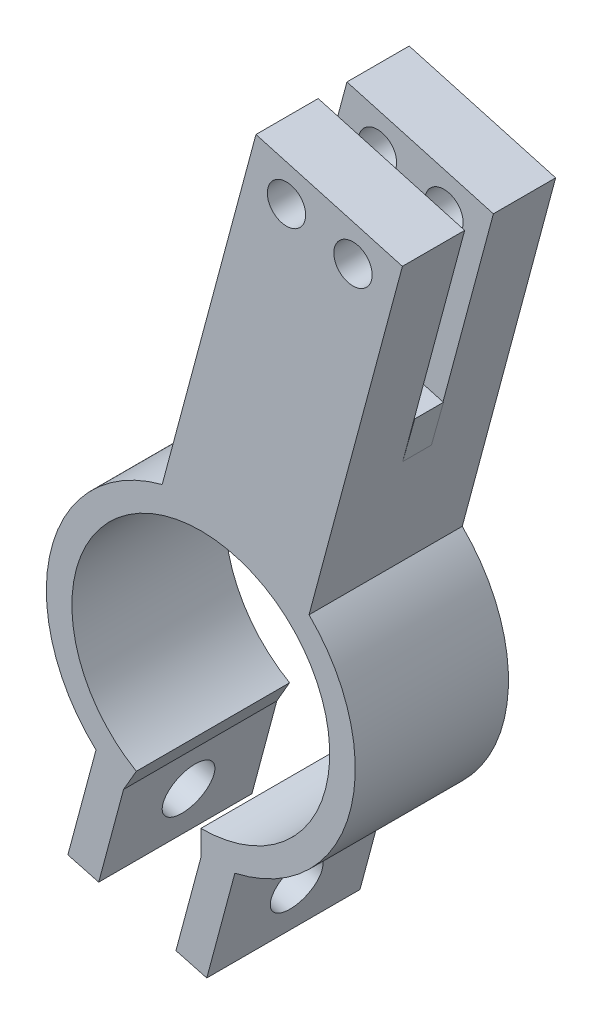
from build123d import *

# Parameters (mm, degrees)
SKETCH1_R                = 24.193
SKETCH1_R_2              = 20.193
BOSS_EXTRUDE1_DEPTH      = 24
CUT_EXTRUDE1_DEPTH       = 24
BOSS_EXTRUDE2_DEPTH      = 24
SKETCH4_R                = 4
CUT_EXTRUDE2_DEPTH       = 24
SKETCH5_R                = 3
BOSS_EXTRUDE3_DEPTH      = 24
CUT_EXTRUDE3_DEPTH       = 37
SKETCH7_W                = 4.5
SKETCH7_H                = 37.5
CUT_EXTRUDE4_DEPTH       = 0.5
SKETCH8_W                = 23.824241379
SKETCH8_H                = 4.5
BOSS_EXTRUDE4_DEPTH      = 6.5
BOSS_EXTRUDE4_DEPTH_BACK = 1


with BuildPart() as part:
    # Sketch1 → Boss-Extrude1 (new body)
    with BuildSketch(Plane.XY):
        Circle(SKETCH1_R)
        Circle(SKETCH1_R_2, mode=Mode.SUBTRACT)
    extrude(amount=BOSS_EXTRUDE1_DEPTH)

    # Sketch2 → Cut-Extrude1 (cut)
    with BuildSketch(Plane.XY.offset(24)):
        Polygon((0, -24.193), (-5.8341998, -24.895299835), (-12.0965, -20.951752594), (0, 0), align=None)
    extrude(amount=-CUT_EXTRUDE1_DEPTH, mode=Mode.SUBTRACT)

    # Sketch3 → Boss-Extrude2 (add)
    with BuildSketch(Plane.XY.offset(24)):
        with BuildLine():
            Line((-15.990029306, -35.482601784), (-12.0965, -20.951752594))
            ThreePointArc((-12.0965, -20.951752594), (-14.346719144, -19.480064138), (-16.419734671, -17.767767512))
            Line((-16.419734671, -17.767767512), (-20.819658437, -34.188506559))
            Line((-20.819658437, -34.188506559), (-15.990029306, -35.482601784))
        make_face()
        with BuildLine():
            ThreePointArc((5.336023592, -23.597205369), (2.684591171, -24.043589982), (0, -24.193))
            Line((0, -24.193), (-3.893529306, -38.72384919))
            Line((-3.893529306, -38.72384919), (0.936099826, -40.017944416))
            Line((0.936099826, -40.017944416), (5.336023592, -23.597205369))
        make_face()
    extrude(amount=-BOSS_EXTRUDE2_DEPTH)

    # Sketch4 → Cut-Extrude2 (cut)
    with BuildSketch(Plane(origin=(-10.877879131, 2.914718929, 0), x_dir=(0, 0, 1), z_dir=(-0.965925826, 0.258819045, 0))):
        with Locations((12, -30.412085563)):
            Circle(SKETCH4_R)
    extrude(amount=-CUT_EXTRUDE2_DEPTH, mode=Mode.SUBTRACT)

    # Sketch5 → Boss-Extrude3 (add)
    with BuildSketch(Plane.XY.offset(24)):
        Polygon((16.953408399, 17.259292937), (31.579228629, 71.843597138), (8.640561787, 78.258704162), (-6.052435886, 23.423690334), align=None)
        with Locations((23.835868108, 68.298098762)):
            Circle(SKETCH5_R, mode=Mode.SUBTRACT)
        with Locations((13.421299193, 71.210673179)):
            Circle(SKETCH5_R, mode=Mode.SUBTRACT)
    extrude(amount=-BOSS_EXTRUDE3_DEPTH)

    # Sketch6 → Cut-Extrude3 (cut)
    with BuildSketch(Plane(origin=(20.925291279, 74.82311416, 0), x_dir=(0.963048124, -0.269329374, 0), z_dir=(0.269329374, 0.963048124, 0))):
        Polygon((-0.846682582, -9.75), (-12.756090991, -9.75), (-12.756090991, -14.25), (-0.846682582, -14.25), (11.062725828, -14.25), (11.062725828, -9.75), align=None)
    extrude(amount=-CUT_EXTRUDE3_DEPTH, mode=Mode.SUBTRACT)

    # Sketch7 → Cut-Extrude4 (cut)
    with BuildSketch(Plane(origin=(11.502922142, -3.082198699, 0), x_dir=(0, 0, -1), z_dir=(0.965925826, -0.258819045, 0))):
        with Locations((-12, 58.818891727)):
            Rectangle(SKETCH7_W, SKETCH7_H)
    extrude(amount=-CUT_EXTRUDE4_DEPTH, mode=Mode.SUBTRACT)

    # Sketch8 → Boss-Extrude4 (add, two sides)
    with BuildSketch(Plane(origin=(10.960104439, 39.190333589, 0), x_dir=(0.963048124, -0.269329374, 0), z_dir=(0.269329374, 0.963048124, 0))) as boss_extrude4_sk:
        with Locations((-0.44075727, -12)):
            Rectangle(SKETCH8_W, SKETCH8_H)
    extrude(amount=BOSS_EXTRUDE4_DEPTH)
    extrude(boss_extrude4_sk.sketch, amount=-BOSS_EXTRUDE4_DEPTH_BACK)


solid = part.part
